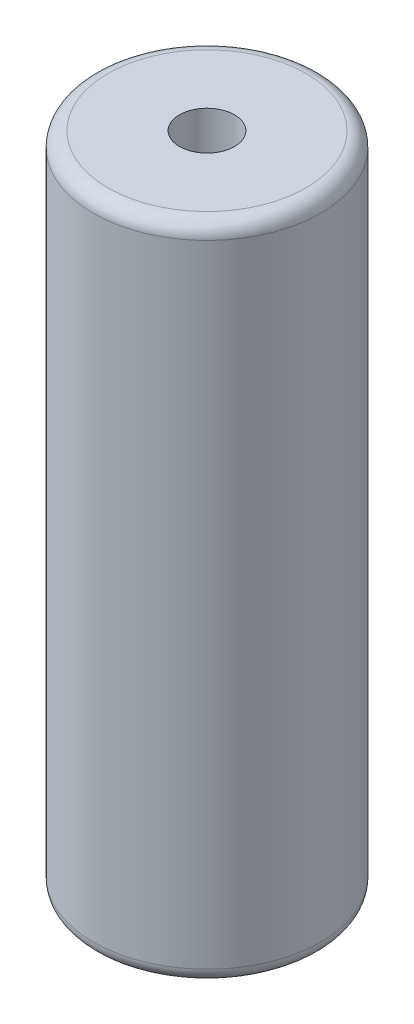
from build123d import *

# Parameters (mm, degrees)
ESQUISSE1_R      = 3.1
ESQUISSE1_R_2    = 0.75
EXTRUSION1_DEPTH = 18
CONG_1_R         = 0.4


with BuildPart() as part:
    # Esquisse1 → Extrusion1 (new body)
    with BuildSketch(Plane(origin=(0, 0, 0), x_dir=(1, 0, 0), z_dir=(0, 1, 0))):
        with Locations(Location((0, 0, 0), (0, 0, 270))):  # turned: the seam where the file's is
            Circle(ESQUISSE1_R)
        with Locations(Location((0, 0, 0), (0, 0, 270))):  # turned: the seam where the file's is
            Circle(ESQUISSE1_R_2, mode=Mode.SUBTRACT)
    extrude(amount=EXTRUSION1_DEPTH)

    # Congé1
    cong_1_edges = [part.edges().sort_by_distance(p)[0] for p in [
        (0, 0, -3.1),
        (0, 18, -3.1),
    ]]
    fillet(cong_1_edges, radius=CONG_1_R)


solid = part.part
